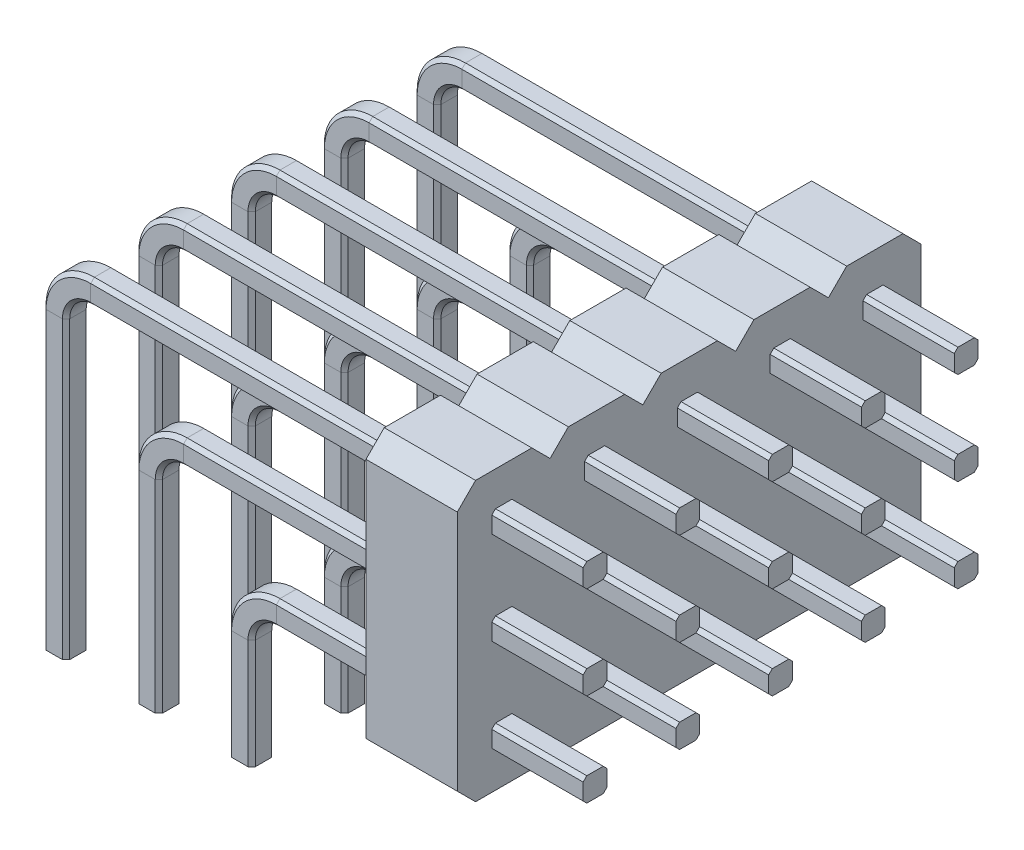
from build123d import *

# Parameters (mm, degrees)
BOSS_EXTRUDE1_DEPTH = 2.5
LPATTERN1_COUNT     = 5
LPATTERN1_PITCH     = 2.54


with BuildPart() as part:
    # Sweep2: sweep along a path in Sketch2
    with BuildLine(Plane.XY) as sweep2_path:
        Line((5.08, 0), (5.08, 3))
        ThreePointArc((5.08, 3), (5.372893219, 3.707106781), (6.08, 4))
        Line((6.08, 4), (14.48, 4))
    # Sketch1 → Sweep2 (sweep)
    with BuildSketch(Plane(origin=(0, 0, 0), x_dir=(1, 0, 0), z_dir=(0, 1, 0))):
        Polygon((4.755, -0.225), (4.755, 0.225), (4.855, 0.325), (5.305, 0.325), (5.405, 0.225), (5.405, -0.225), (5.305, -0.325), (4.855, -0.325), align=None)
    sweep(path=sweep2_path.line)



with BuildPart() as body_2:
    # Sweep3: sweep along a path in Sketch2_7
    with BuildLine(Plane.XY) as sweep3_path:
        Line((2.54, 0), (2.54, 5.54))
        ThreePointArc((2.54, 5.54), (2.832893219, 6.247106781), (3.54, 6.54))
        Line((3.54, 6.54), (14.48, 6.54))
    # Sketch1_3 → Sweep3 (sweep)
    with BuildSketch(Plane(origin=(0, 0, 0), x_dir=(1, 0, 0), z_dir=(0, 1, 0))):
        Polygon((2.215, -0.225), (2.215, 0.225), (2.315, 0.325), (2.765, 0.325), (2.865, 0.225), (2.865, -0.225), (2.765, -0.325), (2.315, -0.325), align=None)
    sweep(path=sweep3_path.line)


with BuildPart() as body_3:
    # Sweep4: sweep along a path in Sketch2_8
    with BuildLine(Plane.XY) as sweep4_path:
        Line((0, 0), (0, 8.08))
        ThreePointArc((0, 8.08), (0.292893219, 8.787106781), (1, 9.08))
        Line((1, 9.08), (14.48, 9.08))
    # Sketch1_4 → Sweep4 (sweep)
    with BuildSketch(Plane(origin=(0, 0, 0), x_dir=(1, 0, 0), z_dir=(0, 1, 0))):
        Polygon((-0.325, 0.225), (-0.225, 0.325), (0.225, 0.325), (0.325, 0.225), (0.325, -0.225), (0.225, -0.325), (-0.225, -0.325), (-0.325, -0.225), align=None)
    sweep(path=sweep4_path.line)


with BuildPart() as part_1:
    add(part.part)

    add(body_2.part)  # Boss-Extrude1 merges body 2

    add(body_3.part)  # Boss-Extrude1 merges body 3
    # Sketch3 → Boss-Extrude1 (add)
    with BuildSketch(Plane(origin=(11.98, 0, 0), x_dir=(0, 0, -1), z_dir=(1, 0, 0))):
        Polygon((0.77, 2.73), (1.27, 3.23), (1.27, 9.85), (0.77, 10.35), (-0.77, 10.35), (-1.27, 9.85), (-1.27, 3.23), (-0.77, 2.73), align=None)
    extrude(amount=-BOSS_EXTRUDE1_DEPTH)


with BuildPart() as lpattern1_1:
    # LPattern1: pattern copy
    add(part_1.part.moved(Location(Vector(0, 0, -1) * (1 * LPATTERN1_PITCH))))


with BuildPart() as lpattern1_2:
    # LPattern1: pattern copy
    add(part_1.part.moved(Location(Vector(0, 0, -1) * (2 * LPATTERN1_PITCH))))


with BuildPart() as lpattern1_3:
    # LPattern1: pattern copy
    add(part_1.part.moved(Location(Vector(0, 0, -1) * (3 * LPATTERN1_PITCH))))


with BuildPart() as lpattern1_4:
    # LPattern1: pattern copy
    add(part_1.part.moved(Location(Vector(0, 0, -1) * (4 * LPATTERN1_PITCH))))


with BuildPart() as part_2:
    add(part_1.part)

    # Combine1: union LPattern1_1, LPattern1_2, LPattern1_3, LPattern1_4
    add(lpattern1_1.part)
    add(lpattern1_2.part)
    add(lpattern1_3.part)
    add(lpattern1_4.part)


solid = part_2.part
